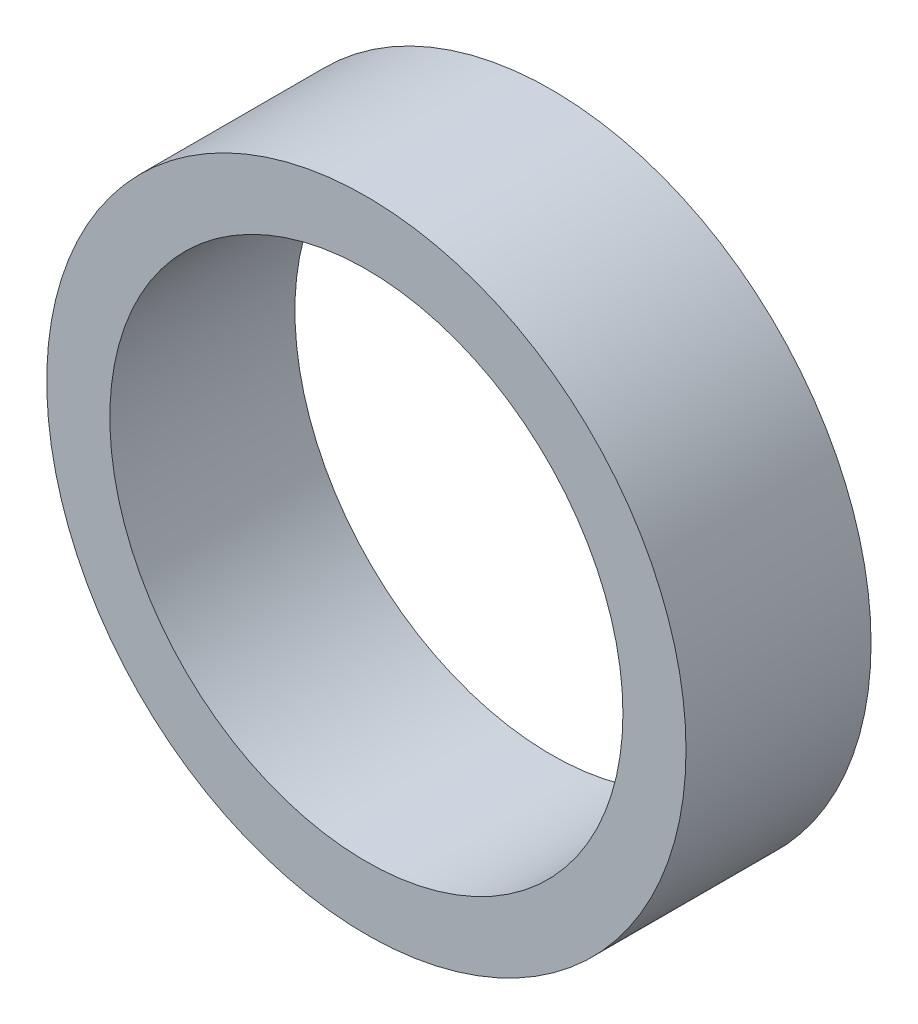
from build123d import *

# Parameters (mm, degrees)
SKETCH1_R           = 19
SKETCH1_R_2         = 15.25
BOSS_EXTRUDE1_DEPTH = 11


with BuildPart() as part:
    # Sketch1 → Boss-Extrude1 (new body)
    with BuildSketch(Plane.XY):
        Circle(SKETCH1_R)
        Circle(SKETCH1_R_2, mode=Mode.SUBTRACT)
    extrude(amount=BOSS_EXTRUDE1_DEPTH)


solid = part.part
